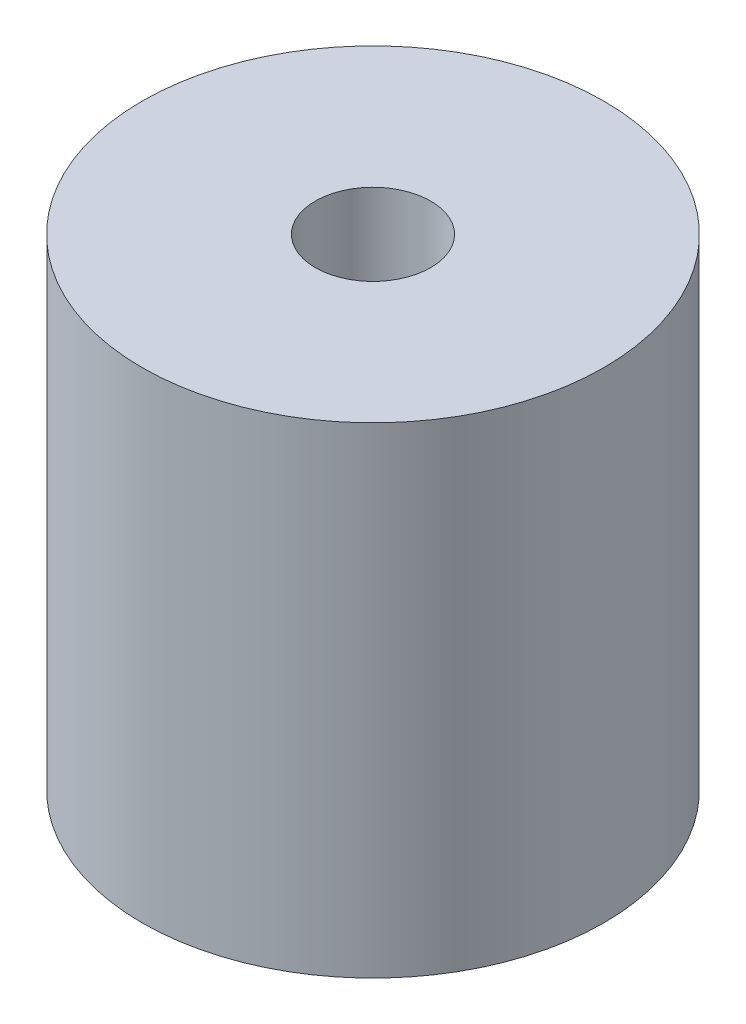
from build123d import *

# Parameters (mm, degrees)
SKETCH1_R           = 24
SKETCH1_R_2         = 6
BOSS_EXTRUDE1_DEPTH = 50


with BuildPart() as part:
    # Sketch1 → Boss-Extrude1 (new body)
    with BuildSketch(Plane(origin=(0, 0, 0), x_dir=(1, 0, 0), z_dir=(0, 1, 0))):
        Circle(SKETCH1_R)
        Circle(SKETCH1_R_2, mode=Mode.SUBTRACT)
    extrude(amount=BOSS_EXTRUDE1_DEPTH)


solid = part.part
